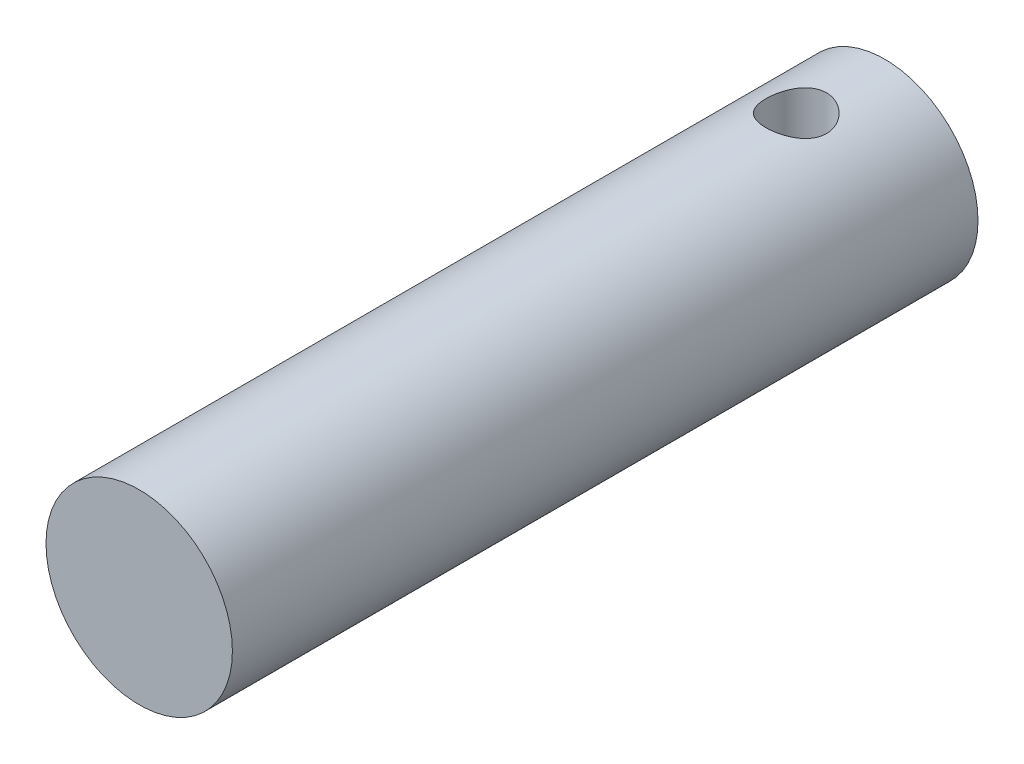
from build123d import *

# Parameters (mm, degrees)
SKETCH_1_R          = 10
EXTRUDE_1_DEPTH     = 80
SKETCH_2_R          = 3.25
CUT_EXTRUDE_1_DEPTH = 210


with BuildPart() as part:
    # 草图1 → 凸台-拉伸1 (new body)
    with BuildSketch(Plane.XY):
        Circle(SKETCH_1_R)
    extrude(amount=EXTRUDE_1_DEPTH)

    # 草图2 → 切除-拉伸1 (cut, symmetric)
    with BuildSketch(Plane(origin=(0, 0, 0), x_dir=(1, 0, 0), z_dir=(0, 1, 0))):
        with Locations((0, -9.5)):
            Circle(SKETCH_2_R)
    extrude(amount=CUT_EXTRUDE_1_DEPTH, both=True, mode=Mode.SUBTRACT)


solid = part.part
